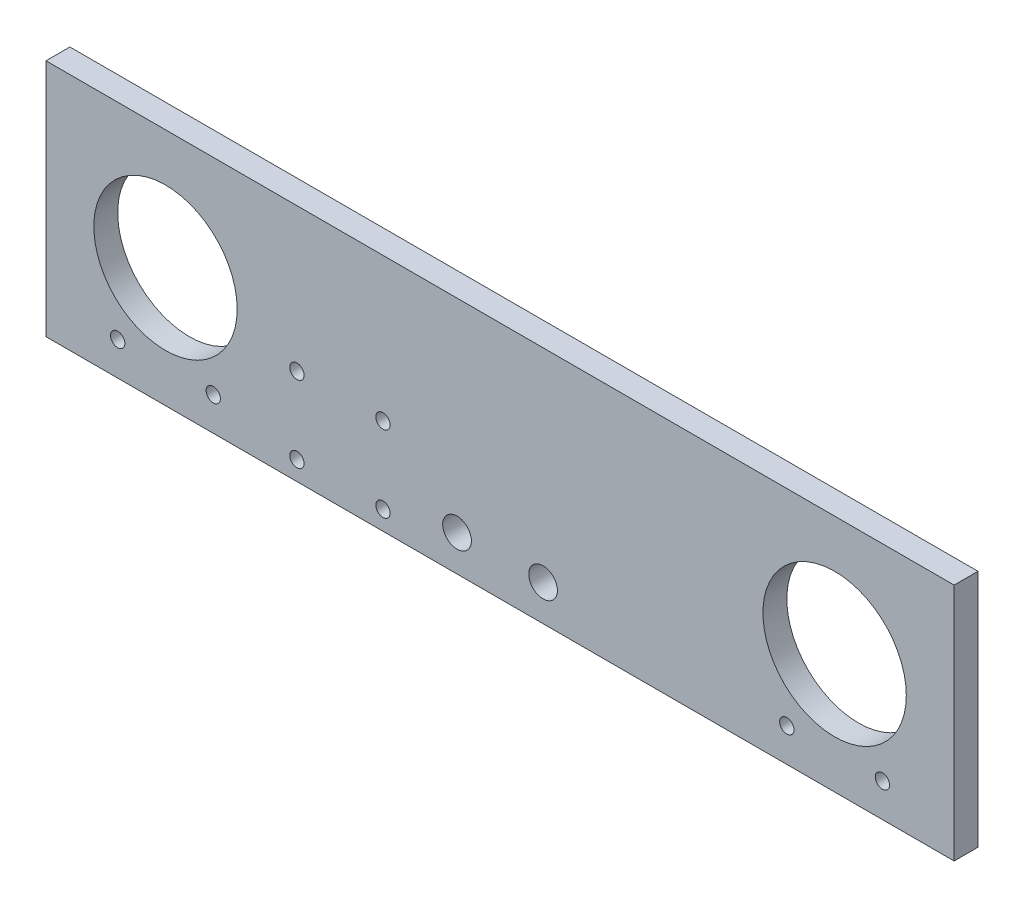
from build123d import *

# Parameters (mm, degrees)
SKETCH1_W           = 190
SKETCH1_H           = 50
SKETCH1_R           = 15
SKETCH1_R_2         = 1.5
SKETCH1_R_3         = 3
BOSS_EXTRUDE1_DEPTH = 5
CUT_EXTRUDE1_START  = -5
SKETCH2_R           = 2.75
CUT_EXTRUDE1_DEPTH  = 1.5


with BuildPart() as part:
    # Sketch1 → Boss-Extrude1 (new body)
    with BuildSketch(Plane.XY):
        with Locations((95, 25)):
            Rectangle(SKETCH1_W, SKETCH1_H)
        with Locations((25, 25)):
            Circle(SKETCH1_R, mode=Mode.SUBTRACT)
        with Locations((165, 25)):
            Circle(SKETCH1_R, mode=Mode.SUBTRACT)
        with Locations((35, 7)):
            Circle(SKETCH1_R_2, mode=Mode.SUBTRACT)
        with Locations((175, 7)):
            Circle(SKETCH1_R_2, mode=Mode.SUBTRACT)
        with Locations((155, 7)):
            Circle(SKETCH1_R_2, mode=Mode.SUBTRACT)
        with Locations((70.5, 20)):
            Circle(SKETCH1_R_2, mode=Mode.SUBTRACT)
        with Locations((86, 7.5)):
            Circle(SKETCH1_R_3, mode=Mode.SUBTRACT)
        with Locations((104, 7.5)):
            Circle(SKETCH1_R_3, mode=Mode.SUBTRACT)
        with Locations((15, 7)):
            Circle(SKETCH1_R_2, mode=Mode.SUBTRACT)
        with Locations((52.5, 4)):
            Circle(SKETCH1_R_2, mode=Mode.SUBTRACT)
        with Locations((52.5, 20)):
            Circle(SKETCH1_R_2, mode=Mode.SUBTRACT)
        with Locations((70.5, 4)):
            Circle(SKETCH1_R_2, mode=Mode.SUBTRACT)
    extrude(amount=BOSS_EXTRUDE1_DEPTH)

    # Sketch2 → Cut-Extrude1 (cut)
    with BuildSketch(Plane.XY.offset(5).offset(CUT_EXTRUDE1_START)):
        with Locations((15, 7)):
            Circle(SKETCH2_R)
        with Locations((35, 7)):
            Circle(SKETCH2_R)
        with Locations((155, 7)):
            Circle(SKETCH2_R)
        with Locations((175, 7)):
            Circle(SKETCH2_R)
    extrude(amount=CUT_EXTRUDE1_DEPTH, mode=Mode.SUBTRACT)


solid = part.part
